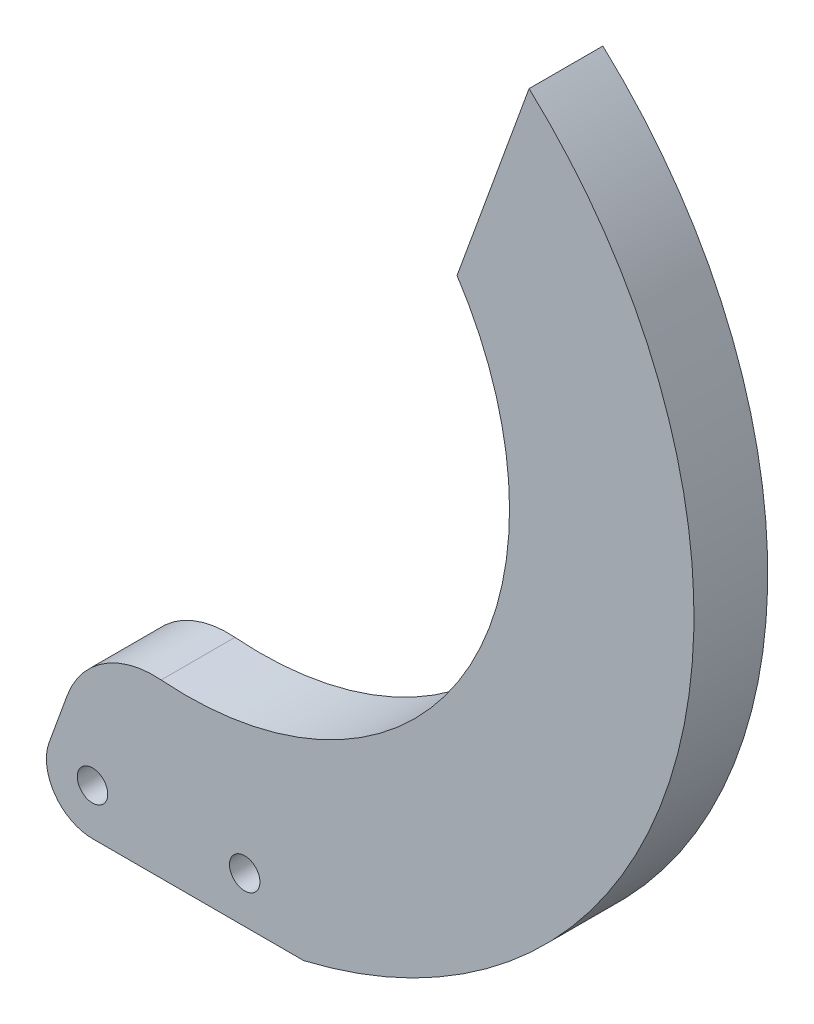
from build123d import *

# Parameters (mm, degrees)
SKETCH_1_R          = 1.65
EXTRUDE_1_DEPTH     = 8
FILLET_1_R          = 10
SKETCH_2_R          = 4
CUT_EXTRUDE_1_DEPTH = 3


with BuildPart() as part:
    # 草圖1 → 填料-伸長1 (new body)
    with BuildSketch(Plane.XY):
        with BuildLine():
            Line((0, -5), (22.896270517, -5))
            ThreePointArc((22.896270517, -5), (63.449308727, 34.693340668), (47.334627368, 89.103149031))
            Line((47.334627368, 89.103149031), (39.525260877, 67.647090937))
            ThreePointArc((39.525260877, 67.647090937), (38.24035653, 27.551768918), (0.138664652, 15))
            Line((0.138664652, 15), (-4.698463104, 1.710100717))
            ThreePointArc((-4.698463104, 1.710100717), (-4.095760221, -2.867882182), (0, -5))
        make_face()
        Circle(SKETCH_1_R, mode=Mode.SUBTRACT)
        with Locations((16.5, 0)):
            Circle(SKETCH_1_R, mode=Mode.SUBTRACT)
    extrude(amount=EXTRUDE_1_DEPTH)

    # 圓角1
    fillet_1_edges = [part.edges().sort_by_distance(p)[0] for p in [
        (0.138664652, 15, 4),
    ]]
    fillet(fillet_1_edges, radius=FILLET_1_R)

    # 草圖2 → 除料-伸長1 (cut)
    with BuildSketch(Plane(origin=(0, 0, 0), x_dir=(-1, 0, 0), z_dir=(0, 0, -1))):
        Circle(SKETCH_2_R)
    extrude(amount=-CUT_EXTRUDE_1_DEPTH, mode=Mode.SUBTRACT)


solid = part.part
